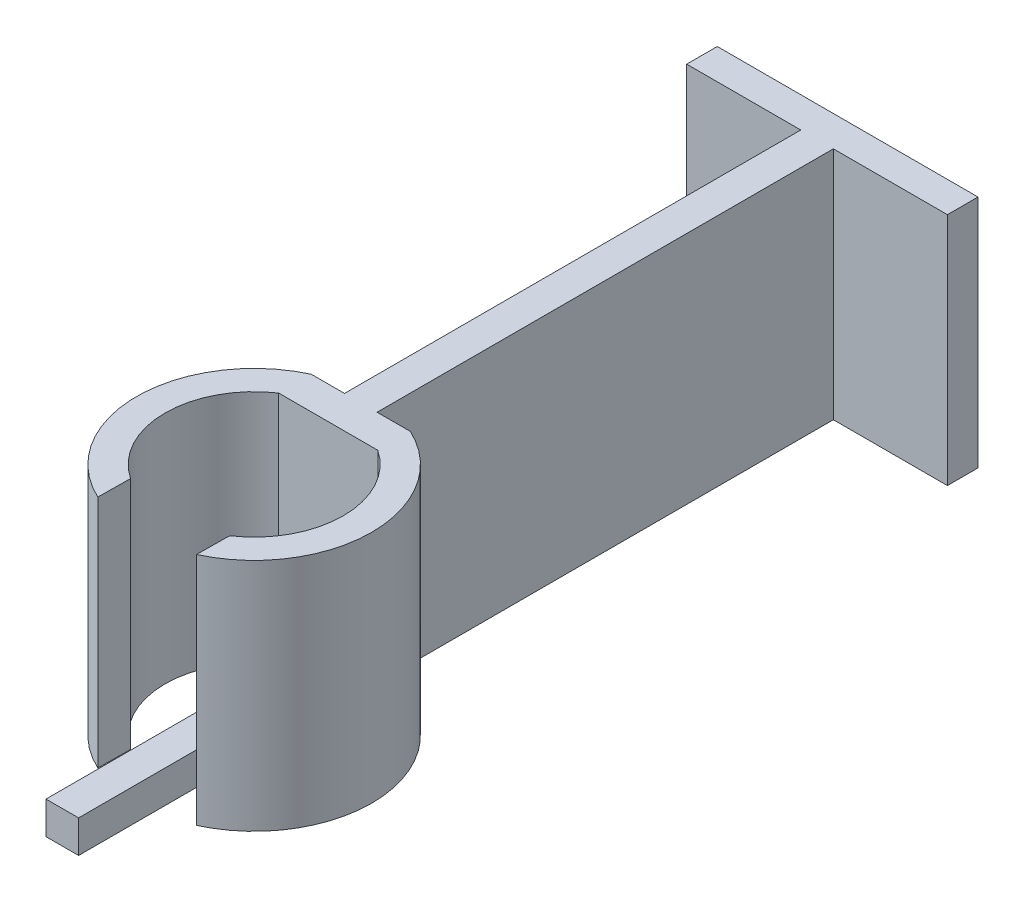
from build123d import *

# Parameters (mm, degrees)
SKETCH1_W                = 3.175
SKETCH1_H                = 44.45
BOSS_EXTRUDE1_DEPTH      = 22.86
SKETCH2_W                = 3.175
SKETCH2_H                = 3.175
BOSS_EXTRUDE2_DEPTH      = 0.508
BOSS_EXTRUDE2_DEPTH_BACK = 26.399527316


with BuildPart() as part:
    # Sketch1 → Boss-Extrude1 (new body)
    with BuildSketch(Plane(origin=(0, 0, 0), x_dir=(1, 0, 0), z_dir=(0, 1, 0))):
        with BuildLine():
            ThreePointArc((9.652, 25.4), (13.507299945, 18.183720298), (9.652, 10.967440596))
            Line((9.652, 10.967440596), (9.61840611, 7.776904574))
            ThreePointArc((9.61840611, 7.776904574), (16.283252173, 18.1652141), (9.652, 28.575))
            Line((9.652, 28.575), (9.652, 25.4))
        make_face()
        Polygon((0, 25.4), (9.652, 25.4), (9.652, 28.575), (6.4135, 28.575), (3.2385, 28.575), (0, 28.575), align=None)
        with BuildLine():
            ThreePointArc((0, 10.967440596), (-3.855299945, 18.183720298), (0, 25.4))
            Line((0, 25.4), (0, 28.575))
            ThreePointArc((0, 28.575), (-6.631251767, 18.202476563), (-0.03399644, 7.808297201))
            Line((-0.03399644, 7.808297201), (0, 10.967440596))
        make_face()
        with Locations((4.826, 50.8)):
            Rectangle(SKETCH1_W, SKETCH1_H)
        Polygon((3.2385, 73.025), (6.4135, 73.025), (17.526, 73.025), (17.526, 76.004634154), (-7.874, 76.004634154), (-7.874, 73.025), align=None)
    extrude(amount=BOSS_EXTRUDE1_DEPTH)


with BuildPart() as body_2:
    # Sketch2 → Boss-Extrude2 (new body, two sides)
    with BuildSketch(Plane.XY) as boss_extrude2_sk:
        with Locations((4.826, 1.5875)):
            Rectangle(SKETCH2_W, SKETCH2_H)
    extrude(amount=BOSS_EXTRUDE2_DEPTH)
    extrude(boss_extrude2_sk.sketch, amount=-BOSS_EXTRUDE2_DEPTH_BACK)


solid = Compound([part.part, body_2.part])
